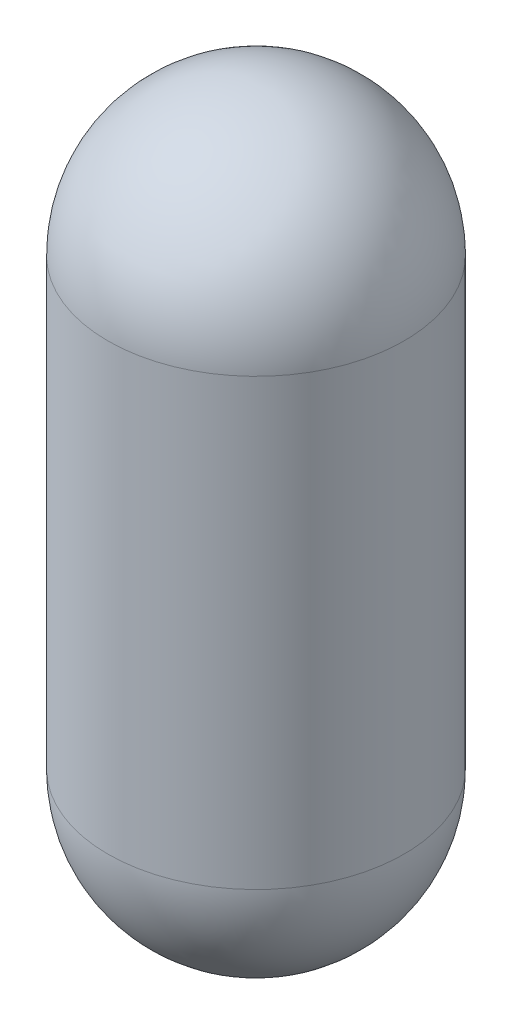
from build123d import *

# Parameters (mm, degrees)
SKETCH1_R           = 25.4
BOSS_EXTRUDE1_DEPTH = 127
FILLET1_R           = 25.4


with BuildPart() as part:
    # Sketch1 → Boss-Extrude1 (new body)
    with BuildSketch(Plane(origin=(0, 0, 0), x_dir=(1, 0, 0), z_dir=(0, 1, 0))):
        Circle(SKETCH1_R)
    extrude(amount=BOSS_EXTRUDE1_DEPTH)

    # Fillet1
    fillet1_edges = [part.edges().sort_by_distance(p)[0] for p in [
        (-25.4, 0, 0),
        (-25.4, 127, 0),
    ]]
    fillet(fillet1_edges, radius=FILLET1_R)


solid = part.part
